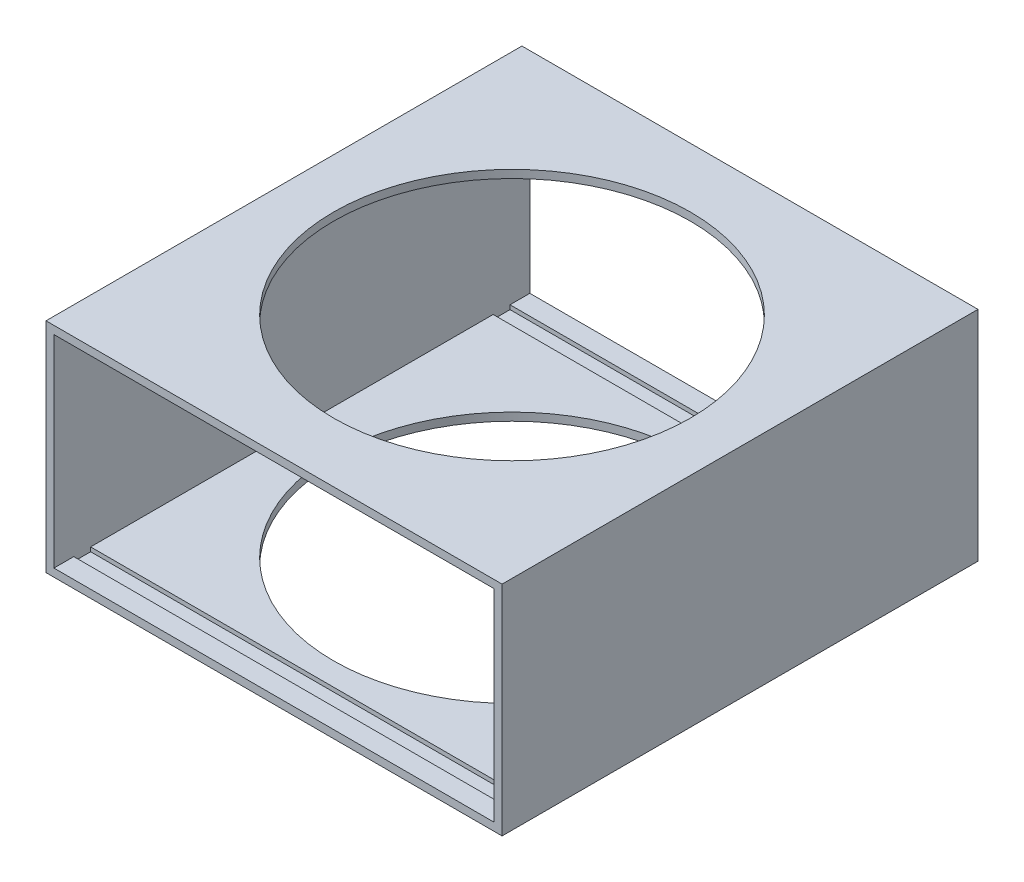
from build123d import *

# Parameters (mm, degrees)
SKETCH4_W               = 115
SKETCH4_H               = 55
SKETCH4_W_2             = 111
SKETCH4_H_2             = 51
FLAT_SURFACE_DEPTH      = 120
SKETCH9_R               = 45
CUT_EXTRUDE1_DEPTH      = 1
CUT_EXTRUDE1_DEPTH_BACK = 55
SKETCH10_W              = 4.252555104
SKETCH10_H              = 1.06386625
CUT_EXTRUDE2_DEPTH      = 111
MIRROR2_COPY_1_SKETCH_W = 4.252555104
MIRROR2_COPY_1_SKETCH_H = 1.06386625
MIRROR2_COPY_1_DEPTH    = 111


with BuildPart() as part:
    # Sketch4 → Flat-surface (new body)
    with BuildSketch(Plane(origin=(0, 0, -80), x_dir=(-1, 0, 0), z_dir=(0, 0, -1))):
        Rectangle(SKETCH4_W, SKETCH4_H)
        Rectangle(SKETCH4_W_2, SKETCH4_H_2, mode=Mode.SUBTRACT)
    extrude(amount=FLAT_SURFACE_DEPTH)

    # Sketch9 → Cut-Extrude1 (cut, two sides)
    with BuildSketch(Plane(origin=(0, 27.5, 0), x_dir=(1, 0, 0), z_dir=(0, 1, 0))) as cut_extrude1_sk:
        with Locations((0, 140)):
            Circle(SKETCH9_R)
    extrude(amount=CUT_EXTRUDE1_DEPTH, mode=Mode.SUBTRACT)
    extrude(cut_extrude1_sk.sketch, amount=-CUT_EXTRUDE1_DEPTH_BACK, mode=Mode.SUBTRACT)

    # Sketch10 → Cut-Extrude2 (cut)
    with BuildSketch(Plane(origin=(-55.5, 0, 0), x_dir=(0, 0, -1), z_dir=(1, 0, 0))):
        with Locations((87.126277552, 26.031933125)):
            Rectangle(SKETCH10_W, SKETCH10_H)
    cut_extrude2 = extrude(amount=CUT_EXTRUDE2_DEPTH, mode=Mode.SUBTRACT)

    # Mirror1: Cut-Extrude2 across plane
    add(cut_extrude2.mirror(Plane.ZX), mode=Mode.SUBTRACT)

    # Mirror2: Cut-Extrude2 across plane
    add(cut_extrude2.mirror(Plane(origin=(0, 0, -140), x_dir=(1, 0, 0), z_dir=(0, 0, -1))), mode=Mode.SUBTRACT)

    # Mirror2 copy 1 sketch → Mirror2 copy 1 (cut)
    with BuildSketch(Plane(origin=(-55.5, 0, -280), x_dir=(0, 0, 1), z_dir=(1, 0, 0))):
        with Locations((87.126277552, 26.031933125)):
            Rectangle(MIRROR2_COPY_1_SKETCH_W, MIRROR2_COPY_1_SKETCH_H)
    extrude(amount=MIRROR2_COPY_1_DEPTH, mode=Mode.SUBTRACT)


solid = part.part
